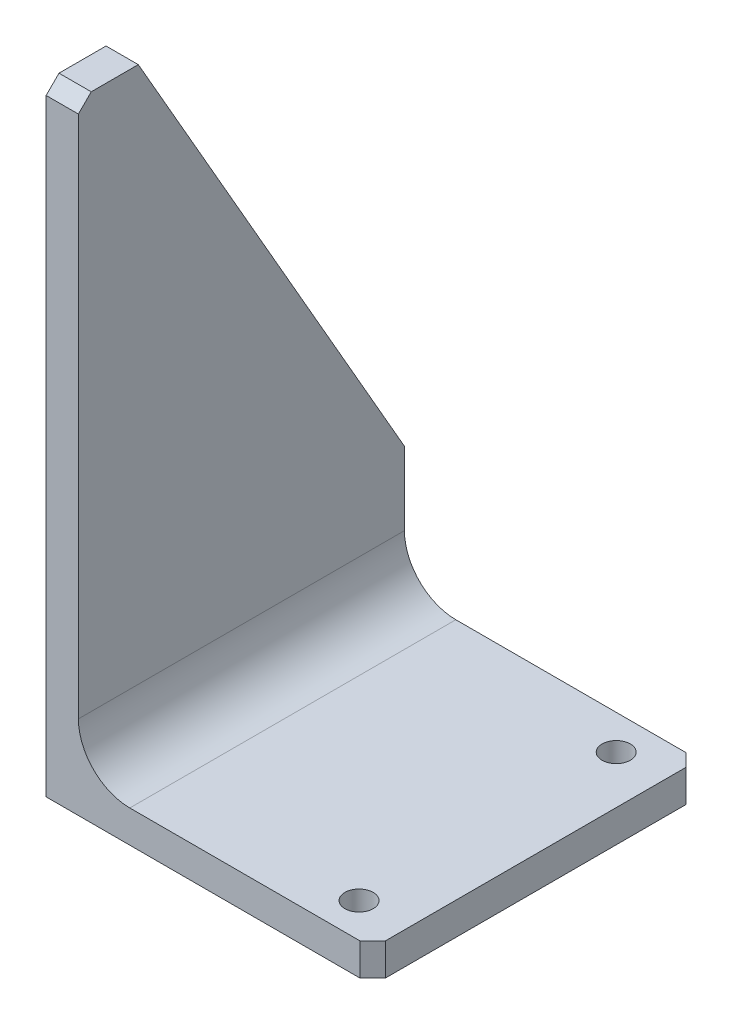
from build123d import *

# Parameters (mm, degrees)
ESBO_O1_W                = 63.48
ESBO_O1_H                = 63.4
RESSALTO_EXTRUS_O1_DEPTH = 6.27
CHANFRO1_SIZE            = 2.5
RESSALTO_EXTRUS_O2_DEPTH = 6.27
CHANFRO2_SIZE            = 2.5
FILETE1_R                = 10
ESBO_O3_R                = 2.75
CORTE_EXTRUS_O1_DEPTH    = 6.27


with BuildPart() as part:
    # Esboço1 → Ressalto-extrusão1 (new body)
    with BuildSketch(Plane(origin=(0, 0, 0), x_dir=(1, 0, 0), z_dir=(0, 1, 0))):
        Rectangle(ESBO_O1_W, ESBO_O1_H)
    extrude(amount=RESSALTO_EXTRUS_O1_DEPTH)

    # Chanfro1
    chanfro1_edges = [part.edges().sort_by_distance(p)[0] for p in [
        (31.74, 3.135, -31.7),
        (31.74, 3.135, 31.7),
    ]]
    chamfer(chanfro1_edges, length=CHANFRO1_SIZE)

    # Esboço2 → Ressalto-extrusão2 (add)
    with BuildSketch(Plane.ZY.offset(25.49)):
        Polygon((-31.7, 30.5), (-31.7, 0), (31.7, 0), (31.7, 30.5), (31.7, 120.63), (20.05, 120.63), align=None)
    extrude(amount=RESSALTO_EXTRUS_O2_DEPTH)

    # Chanfro2
    chanfro2_edges = [part.edges().sort_by_distance(p)[0] for p in [
        (-28.625, 120.63, 31.7),
    ]]
    chamfer(chanfro2_edges, length=CHANFRO2_SIZE)

    # Filete1
    filete1_edges = [part.edges().sort_by_distance(p)[0] for p in [
        (-25.49, 6.27, 0),
    ]]
    fillet(filete1_edges, radius=FILETE1_R)

    # Esboço3 → Corte-extrusão1 (cut)
    with BuildSketch(Plane(origin=(0, 0, 0), x_dir=(-1, 0, 0), z_dir=(0, -1, 0))):
        with Locations((-22.39, -25)):
            Circle(ESBO_O3_R)
        with Locations((-22.39, 25)):
            Circle(ESBO_O3_R)
    extrude(amount=-CORTE_EXTRUS_O1_DEPTH, mode=Mode.SUBTRACT)


solid = part.part
